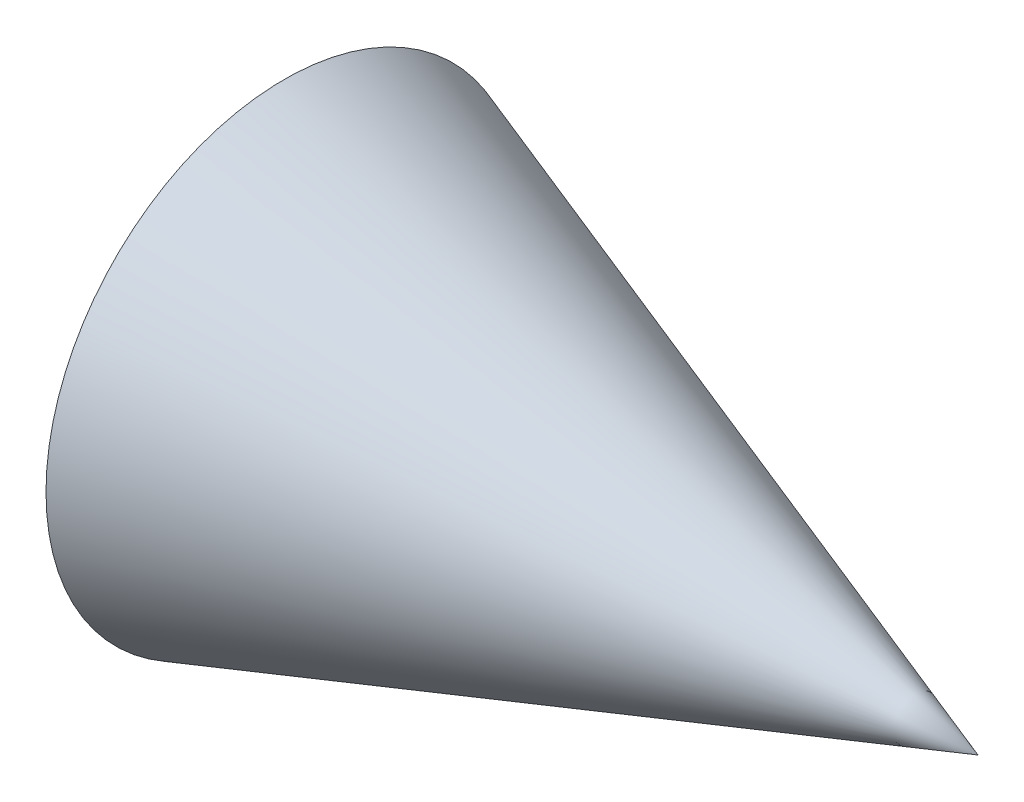
from build123d import *


with BuildPart() as part:
    # Sketch1 → Revolve1 (revolve)
    with BuildSketch(Plane.XY):
        Polygon((0, 0), (0, 5.2), (15.142857143, 0), align=None)
    revolve(axis=Axis((-35.714285714, 0, 0), (1, 0, 0)))


solid = part.part
